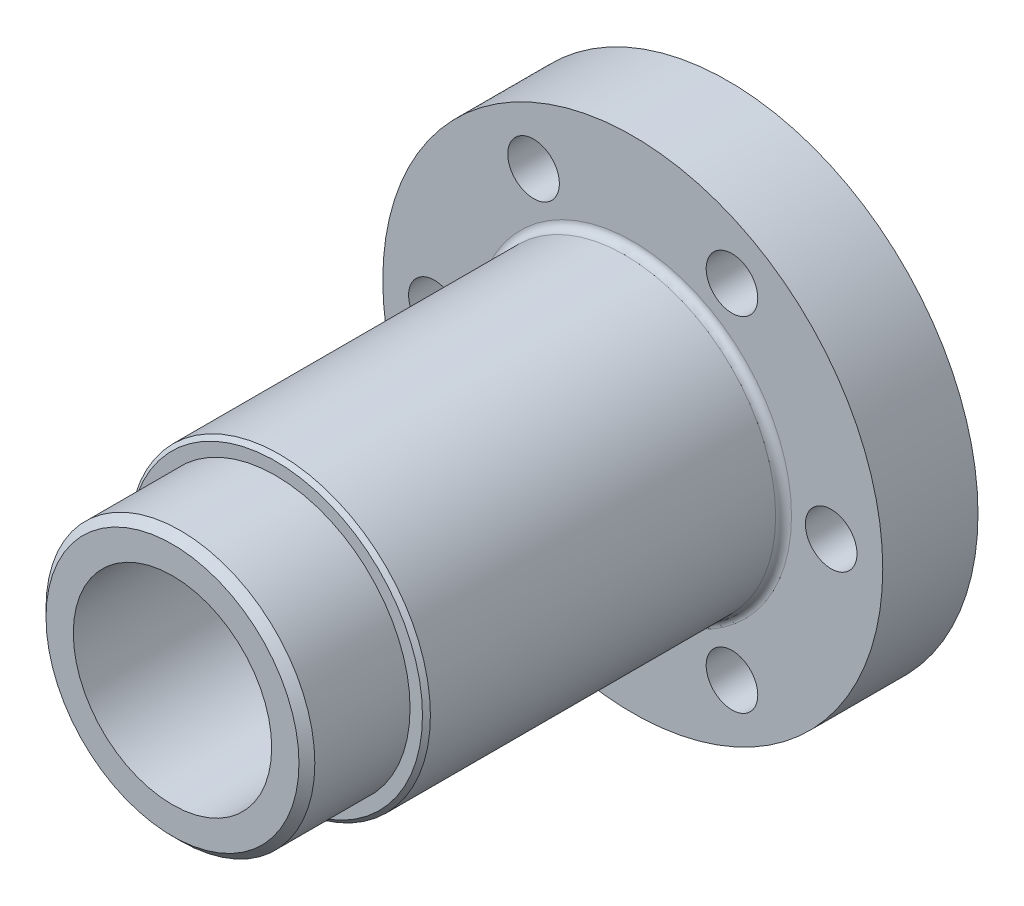
from build123d import *

# Parameters (mm, degrees)
SKETCH1_R                  = 31.5
BOSS_EXTRUDE1_DEPTH        = 12
SKETCH3_R                  = 15.75
BOSS_EXTRUDE2_DEPTH        = 6
F_6_5_6_5_DIAMETER_HOLE1_D = 6.5
SKETCH14_R                 = 19
BOSS_EXTRUDE4_DEPTH        = 45
CHAMFER2_SIZE              = 0.5
FILLET3_R                  = 1
SKETCH15_R                 = 16.9375
BOSS_EXTRUDE6_DEPTH        = 13
CHAMFER3_SIZE              = 1
CHAMFER6_SIZE              = 0.5
F_25_0MM_DOWEL_HOLE1_D     = 25
F_25_0MM_DOWEL_HOLE1_DEPTH = 45
F_25_0MM_DOWEL_HOLE1_TIP   = 7.510757738


with BuildPart() as part:
    # Sketch1 → Boss-Extrude1 (new body)
    with BuildSketch(Plane.XY):
        Circle(SKETCH1_R)
    extrude(amount=BOSS_EXTRUDE1_DEPTH)

    # Sketch3 → Boss-Extrude2 (add)
    with BuildSketch(Plane(origin=(0, 0, 0), x_dir=(-1, 0, 0), z_dir=(0, 0, -1))):
        Circle(SKETCH3_R)
    extrude(amount=BOSS_EXTRUDE2_DEPTH)

    # Ø6.5 (6.5) Diameter Hole1 (through all)
    with Locations(Plane.XY.offset(12)):
        with Locations((-12.5, 21.650635095), (-25, 0), (-12.5, -21.650635095), (12.5, -21.650635095), (25, 0), (12.5, 21.650635095)):
            Hole(F_6_5_6_5_DIAMETER_HOLE1_D / 2)

    # Sketch14 → Boss-Extrude4 (add)
    with BuildSketch(Plane.XY.offset(12)):
        Circle(SKETCH14_R)
    extrude(amount=BOSS_EXTRUDE4_DEPTH)

    # Chamfer2
    chamfer2_edges = [part.edges().sort_by_distance(p)[0] for p in [
        (-19, 0, 57),
    ]]
    chamfer(chamfer2_edges, length=CHAMFER2_SIZE)

    # Fillet3
    fillet3_edges = [part.edges().sort_by_distance(p)[0] for p in [
        (-19, 0, 12),
    ]]
    fillet(fillet3_edges, radius=FILLET3_R)

    # Sketch15 → Boss-Extrude6 (add)
    with BuildSketch(Plane.XY.offset(57)):
        Circle(SKETCH15_R)
    extrude(amount=BOSS_EXTRUDE6_DEPTH)

    # Chamfer3
    chamfer3_edges = [part.edges().sort_by_distance(p)[0] for p in [
        (-16.9375, 0, 70),
    ]]
    chamfer(chamfer3_edges, length=CHAMFER3_SIZE)

    # Chamfer6
    chamfer6_edges = [part.edges().sort_by_distance(p)[0] for p in [
        (15.75, 0, -6),
    ]]
    chamfer(chamfer6_edges, length=CHAMFER6_SIZE)

    # Ø25.0mm Dowel Hole1
    with Locations(Plane.XY.offset(70)):
        with Locations((0, 0)):
            Hole(F_25_0MM_DOWEL_HOLE1_D / 2, depth=F_25_0MM_DOWEL_HOLE1_DEPTH)
            with Locations((0, 0, -(F_25_0MM_DOWEL_HOLE1_DEPTH + F_25_0MM_DOWEL_HOLE1_TIP / 2))):  # 118° drill point
                Cone(0, F_25_0MM_DOWEL_HOLE1_D / 2, F_25_0MM_DOWEL_HOLE1_TIP, mode=Mode.SUBTRACT)


solid = part.part
